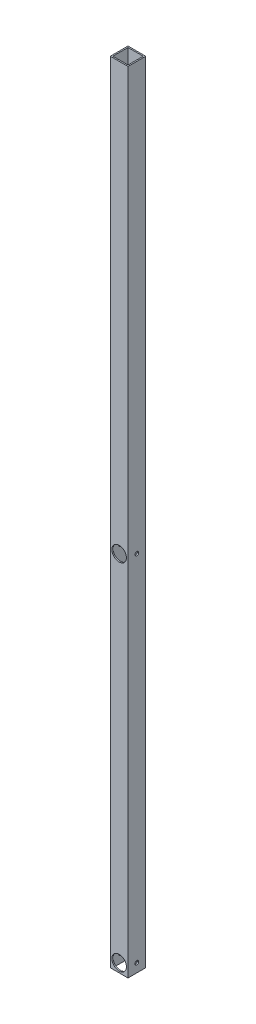
from build123d import *

# Parameters (mm, degrees)
SKETCH1_W           = 44.45
SKETCH1_H           = 44.45
SKETCH1_W_2         = 38.1
SKETCH1_H_2         = 38.1
BOSS_EXTRUDE1_DEPTH = 1981.2
SKETCH2_R           = 18.25625
CUT_EXTRUDE1_DEPTH  = 45.45
SKETCH3_R           = 4.7625
CUT_EXTRUDE2_DEPTH  = 45.45


with BuildPart() as part:
    # Sketch1 → Boss-Extrude1 (new body)
    with BuildSketch(Plane(origin=(0, 0, 0), x_dir=(1, 0, 0), z_dir=(0, 1, 0))):
        with Locations((22.225, 22.225)):
            Rectangle(SKETCH1_W, SKETCH1_H)
        with Locations((22.225, 22.225)):
            Rectangle(SKETCH1_W_2, SKETCH1_H_2, mode=Mode.SUBTRACT)
    extrude(amount=BOSS_EXTRUDE1_DEPTH)

    # Sketch2 → Cut-Extrude1 (cut, through all)
    with BuildSketch(Plane.XY):
        with Locations((22.225, 22.225)):
            Circle(SKETCH2_R)
        with Locations((22.225, 911.225)):
            Circle(SKETCH2_R)
    extrude(amount=-CUT_EXTRUDE1_DEPTH, mode=Mode.SUBTRACT)

    # Sketch3 → Cut-Extrude2 (cut, through all)
    with BuildSketch(Plane(origin=(44.45, 0, 0), x_dir=(0, 0, -1), z_dir=(1, 0, 0))):
        with Locations((22.225, 22.225)):
            Circle(SKETCH3_R)
        with Locations((22.225, 911.225)):
            Circle(SKETCH3_R)
    extrude(amount=-CUT_EXTRUDE2_DEPTH, mode=Mode.SUBTRACT)


solid = part.part
